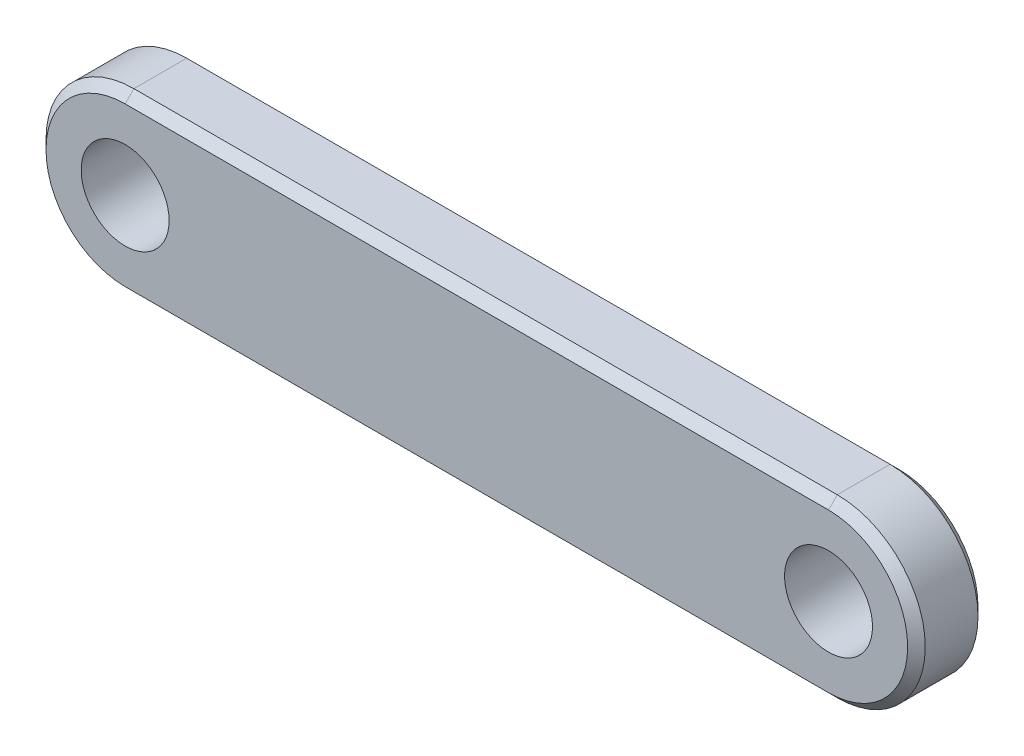
from build123d import *

# Parameters (mm, degrees)
SKETCH1_R           = 2.5
BOSS_EXTRUDE1_DEPTH = 4
CHAMFER1_SIZE       = 0.5


with BuildPart() as part:
    # Sketch1 → Boss-Extrude1 (new body)
    with BuildSketch(Plane.XY):
        with BuildLine():
            Line((-20, 5), (20, 5))
            ThreePointArc((20, 5), (25, 0), (20, -5))
            Line((20, -5), (-20, -5))
            ThreePointArc((-20, -5), (-25, 0), (-20, 5))
        make_face()
        with Locations((-20, 0)):
            Circle(SKETCH1_R, mode=Mode.SUBTRACT)
        with Locations((20, 0)):
            Circle(SKETCH1_R, mode=Mode.SUBTRACT)
    extrude(amount=-BOSS_EXTRUDE1_DEPTH)

    # Chamfer1
    chamfer1_edges = [part.edges().sort_by_distance(p)[0] for p in [
        (25, 0, -4),
        (0, 5, -4),
        (-25, 0, -4),
        (0, 5, 0),
        (25, 0, 0),
        (0, -5, 0),
        (-25, 0, 0),
        (0, -5, -4),
    ]]
    chamfer(chamfer1_edges, length=CHAMFER1_SIZE)


solid = part.part
